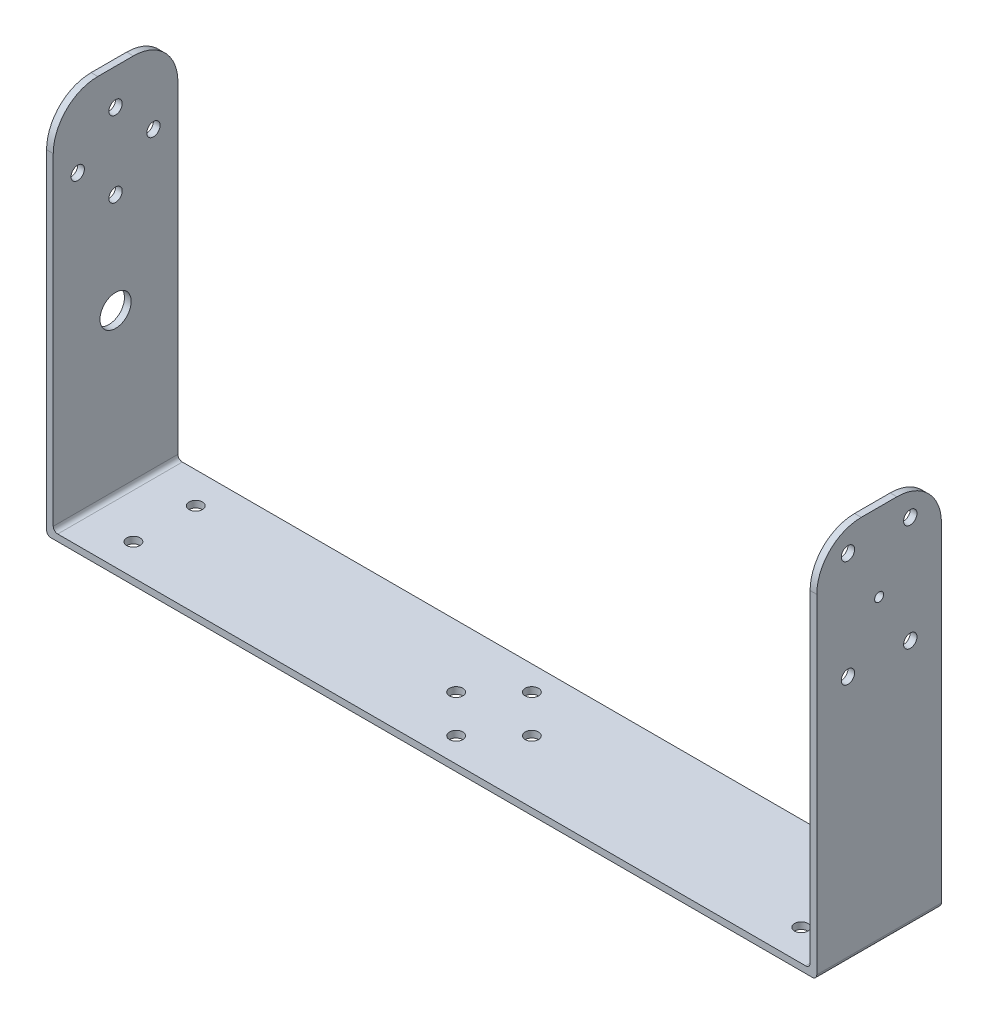
from build123d import *

# Parameters (mm, degrees)
SKETCH1_W               = 170
SKETCH1_H               = 28
BOSS_EXTRUDE1_DEPTH     = 1.5
SKETCH2_W               = 28
SKETCH2_H               = 85
BOSS_EXTRUDE2_DEPTH     = 1.5
FILLET2_R               = 10
FILLET3_R               = 1
FILLET4_R               = 1
SKETCH5_R               = 1.5
CUT_EXTRUDE2_DEPTH      = 15
CUT_EXTRUDE2_DEPTH_BACK = 15
SKETCH7_R               = 3.5
CUT_EXTRUDE3_DEPTH      = 15
CUT_EXTRUDE3_DEPTH_BACK = 15
SKETCH8_R               = 1.5
CUT_EXTRUDE4_DEPTH      = 15
CUT_EXTRUDE4_DEPTH_BACK = 15
SKETCH11_W              = 28
SKETCH11_H              = 85
SKETCH11_R              = 1
BOSS_EXTRUDE5_DEPTH     = 1.5
FILLET5_R               = 1
FILLET6_R               = 1
FILLET7_R               = 10
FILLET8_R               = 10
SKETCH12_R              = 1.5
CUT_EXTRUDE5_DEPTH      = 10
CUT_EXTRUDE5_DEPTH_BACK = 10
SKETCH13_R              = 1.5
CUT_EXTRUDE6_DEPTH      = 10
CUT_EXTRUDE6_DEPTH_BACK = 10


with BuildPart() as part:
    # Sketch1 → Boss-Extrude1 (new body)
    with BuildSketch(Plane(origin=(0, 0, 0), x_dir=(1, 0, 0), z_dir=(0, 1, 0))):
        with Locations((85, 14)):
            Rectangle(SKETCH1_W, SKETCH1_H)
    extrude(amount=BOSS_EXTRUDE1_DEPTH)

    # Sketch2 → Boss-Extrude2 (add)
    with BuildSketch(Plane(origin=(0, 0, 0), x_dir=(0, 0, -1), z_dir=(1, 0, 0))):
        with Locations((14, 42.5)):
            Rectangle(SKETCH2_W, SKETCH2_H)
    extrude(amount=-BOSS_EXTRUDE2_DEPTH)

    # Fillet2
    fillet2_edges = [part.edges().sort_by_distance(p)[0] for p in [
        (-0.75, 85, -28),
        (-0.75, 85, 0),
    ]]
    fillet(fillet2_edges, radius=FILLET2_R)

    # Fillet3
    fillet3_edges = [part.edges().sort_by_distance(p)[0] for p in [
        (-1.5, 0, -14),
    ]]
    fillet(fillet3_edges, radius=FILLET3_R)

    # Fillet4
    fillet4_edges = [part.edges().sort_by_distance(p)[0] for p in [
        (0, 1.5, -14),
    ]]
    fillet(fillet4_edges, radius=FILLET4_R)

    # Sketch5 → Cut-Extrude2 (cut, two sides)
    with BuildSketch(Plane(origin=(0, 0, 0), x_dir=(0, 0, -1), z_dir=(1, 0, 0))) as cut_extrude2_sk:
        with Locations((14, 77)):
            Circle(SKETCH5_R)
        with Locations((14, 60)):
            Circle(SKETCH5_R)
        with Locations((22.5, 68.5)):
            Circle(SKETCH5_R)
        with Locations((5.5, 68.5)):
            Circle(SKETCH5_R)
    extrude(amount=CUT_EXTRUDE2_DEPTH, mode=Mode.SUBTRACT)
    extrude(cut_extrude2_sk.sketch, amount=-CUT_EXTRUDE2_DEPTH_BACK, mode=Mode.SUBTRACT)

    # Sketch7 → Cut-Extrude3 (cut, two sides)
    with BuildSketch(Plane(origin=(0, 0, 0), x_dir=(0, 0, -1), z_dir=(1, 0, 0))) as cut_extrude3_sk:
        with Locations((14, 37.5)):
            Circle(SKETCH7_R)
    extrude(amount=CUT_EXTRUDE3_DEPTH, mode=Mode.SUBTRACT)
    extrude(cut_extrude3_sk.sketch, amount=-CUT_EXTRUDE3_DEPTH_BACK, mode=Mode.SUBTRACT)

    # Sketch8 → Cut-Extrude4 (cut, two sides)
    with BuildSketch(Plane(origin=(0, 1.5, 0), x_dir=(1, 0, 0), z_dir=(0, 1, 0))) as cut_extrude4_sk:
        with Locations((161, 7)):
            Circle(SKETCH8_R)
        with Locations((11, 21)):
            Circle(SKETCH8_R)
        with Locations((11, 7)):
            Circle(SKETCH8_R)
        with Locations((161, 21)):
            Circle(SKETCH8_R)
    extrude(amount=CUT_EXTRUDE4_DEPTH, mode=Mode.SUBTRACT)
    extrude(cut_extrude4_sk.sketch, amount=-CUT_EXTRUDE4_DEPTH_BACK, mode=Mode.SUBTRACT)

    # Sketch11 → Boss-Extrude5 (add)
    with BuildSketch(Plane(origin=(170, 0, 0), x_dir=(0, 0, -1), z_dir=(1, 0, 0))):
        with Locations((14, 42.5)):
            Rectangle(SKETCH11_W, SKETCH11_H)
        with Locations((14, 67.5)):
            Circle(SKETCH11_R, mode=Mode.SUBTRACT)
    extrude(amount=BOSS_EXTRUDE5_DEPTH)

    # Fillet5
    fillet5_edges = [part.edges().sort_by_distance(p)[0] for p in [
        (170, 1.5, -14),
    ]]
    fillet(fillet5_edges, radius=FILLET5_R)

    # Fillet6
    fillet6_edges = [part.edges().sort_by_distance(p)[0] for p in [
        (171.5, 0, -14),
    ]]
    fillet(fillet6_edges, radius=FILLET6_R)

    # Fillet7
    fillet7_edges = [part.edges().sort_by_distance(p)[0] for p in [
        (170.75, 85, 0),
    ]]
    fillet(fillet7_edges, radius=FILLET7_R)

    # Fillet8
    fillet8_edges = [part.edges().sort_by_distance(p)[0] for p in [
        (170.75, 85, -28),
    ]]
    fillet(fillet8_edges, radius=FILLET8_R)

    # Sketch12 → Cut-Extrude5 (cut, two sides)
    with BuildSketch(Plane.ZY.offset(-170)) as cut_extrude5_sk:
        with Locations((-21, 79.5)):
            Circle(SKETCH12_R)
        with Locations((-7, 79.5)):
            Circle(SKETCH12_R)
        with Locations((-7, 55.5)):
            Circle(SKETCH12_R)
        with Locations((-21, 55.5)):
            Circle(SKETCH12_R)
    extrude(amount=CUT_EXTRUDE5_DEPTH, mode=Mode.SUBTRACT)
    extrude(cut_extrude5_sk.sketch, amount=-CUT_EXTRUDE5_DEPTH_BACK, mode=Mode.SUBTRACT)

    # Sketch13 → Cut-Extrude6 (cut, two sides)
    with BuildSketch(Plane(origin=(0, 1.5, 0), x_dir=(1, 0, 0), z_dir=(0, 1, 0))) as cut_extrude6_sk:
        with Locations((85, 22.5)):
            Circle(SKETCH13_R)
        with Locations((85, 5.5)):
            Circle(SKETCH13_R)
        with Locations((93.5, 14)):
            Circle(SKETCH13_R)
        with Locations((76.5, 14)):
            Circle(SKETCH13_R)
    extrude(amount=CUT_EXTRUDE6_DEPTH, mode=Mode.SUBTRACT)
    extrude(cut_extrude6_sk.sketch, amount=-CUT_EXTRUDE6_DEPTH_BACK, mode=Mode.SUBTRACT)


solid = part.part
